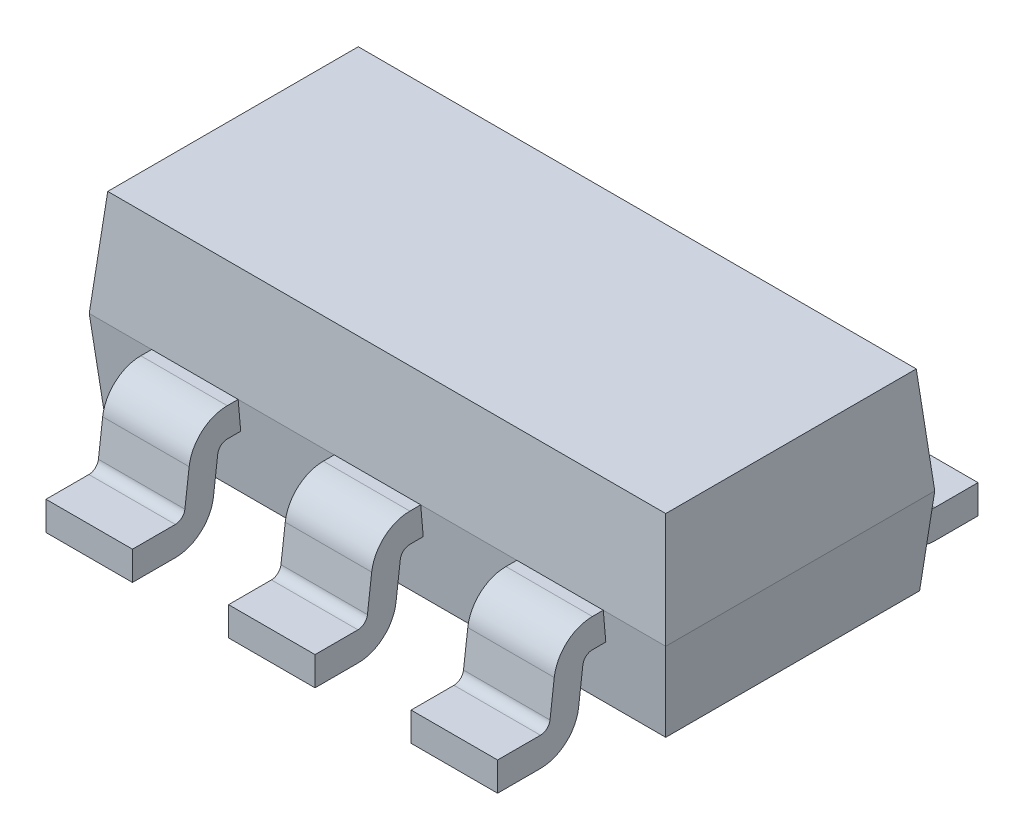
from build123d import *

# Parameters (mm, degrees)
SKETCH1_W                = 3
SKETCH1_H                = 1.4
EXTRUDE1_DEPTH           = 0.55
EXTRUDE1_TAPER           = 5
EXTRUDE1_OTHER_WAY_DEPTH = 0.45
EXTRUDE1_OTHER_WAY_TAPER = 5
EXTRUDE2_DEPTH           = 0.225
EXTRUDE2_DEPTH_BACK      = 0.225
EXTRUDE3_START           = 0.95
EXTRUDE3_DEPTH           = 0.225
MIRROR_START             = 0.95
MIRROR_1_COPY_1_DEPTH    = 0.225
FILLET1_R                = 0.05
FILLET2_R                = 0.2


with BuildPart() as part:
    # Sketch1 → Extrude1 (new body)
    with BuildSketch(Plane(origin=(0, 0, 0), x_dir=(1, 0, 0), z_dir=(0, 1, 0))):
        Rectangle(SKETCH1_W, SKETCH1_H)
    extrude(amount=EXTRUDE1_DEPTH, taper=EXTRUDE1_TAPER)

    # Sketch1 → Extrude1 other way (add)
    with BuildSketch(Plane(origin=(0, 0, 0), x_dir=(1, 0, 0), z_dir=(0, 1, 0))):
        Rectangle(SKETCH1_W, SKETCH1_H)
    extrude(amount=-EXTRUDE1_OTHER_WAY_DEPTH, taper=EXTRUDE1_OTHER_WAY_TAPER)

    # Sketch2 → Extrude2 (add, two sides)
    with BuildSketch(Plane(origin=(0, 0, 0), x_dir=(0, 0, -1), z_dir=(1, 0, 0))) as extrude2_sk:
        Polygon((-0.585273808, 0), (-0.933594965, 0), (-0.98270879, -0.4), (-1.25, -0.4), (-1.25, -0.55), (-0.85, -0.55), (-0.800886176, -0.15), (-0.585273808, -0.15), align=None)
    extrude(amount=EXTRUDE2_DEPTH)
    extrude(extrude2_sk.sketch, amount=-EXTRUDE2_DEPTH_BACK)

    # Sketch2_3 → Extrude3 (add, symmetric)
    with BuildSketch(Plane(origin=(0, 0, 0), x_dir=(0, 0, -1), z_dir=(1, 0, 0)).offset(EXTRUDE3_START)):
        Polygon((0.585273808, 0), (0.933594965, 0), (0.98270879, -0.4), (1.25, -0.4), (1.25, -0.55), (0.85, -0.55), (0.800886176, -0.15), (0.585273808, -0.15), align=None)
    extrude3 = extrude(amount=EXTRUDE3_DEPTH, both=True)

    # Mirror1: Extrude3 across plane
    add(extrude3.mirror(Plane(origin=(0, 0, 0), x_dir=(0, 0, 1), z_dir=(1, 0, 0))))

    # Mirror 1: Extrude3 across plane
    add(extrude3.mirror(Plane.XY))

    # Mirror 1 copy 1 sketch → Mirror 1 copy 1 (add, symmetric)
    with BuildSketch(Plane.ZY.offset(MIRROR_START)):
        Polygon((0.585273808, 0), (0.933594965, 0), (0.98270879, -0.4), (1.25, -0.4), (1.25, -0.55), (0.85, -0.55), (0.800886176, -0.15), (0.585273808, -0.15), align=None)
    extrude(amount=MIRROR_1_COPY_1_DEPTH, both=True)

    # Fillet1
    fillet1_edges = [part.edges().sort_by_distance(p)[0] for p in [
        (0.95, -0.4, 0.98270879),
        (0.95, -0.15, 0.800886176),
        (-0.95, -0.15, 0.800886176),
        (-0.95, -0.4, 0.98270879),
        (0, -0.4, 0.98270879),
        (0, -0.15, 0.800886176),
        (0.95, -0.15, -0.800886176),
        (0.95, -0.4, -0.98270879),
        (-0.95, -0.4, -0.98270879),
        (-0.95, -0.15, -0.800886176),
    ]]
    fillet(fillet1_edges, radius=FILLET1_R)

    # Fillet2
    fillet2_edges = [part.edges().sort_by_distance(p)[0] for p in [
        (0.95, 0, 0.933594965),
        (0.95, -0.55, 0.85),
        (-0.95, 0, 0.933594965),
        (-0.95, -0.55, 0.85),
        (0, 0, 0.933594965),
        (0, -0.55, 0.85),
        (0.95, 0, -0.933594965),
        (0.95, -0.55, -0.85),
        (-0.95, 0, -0.933594965),
        (-0.95, -0.55, -0.85),
    ]]
    fillet(fillet2_edges, radius=FILLET2_R)


solid = part.part
